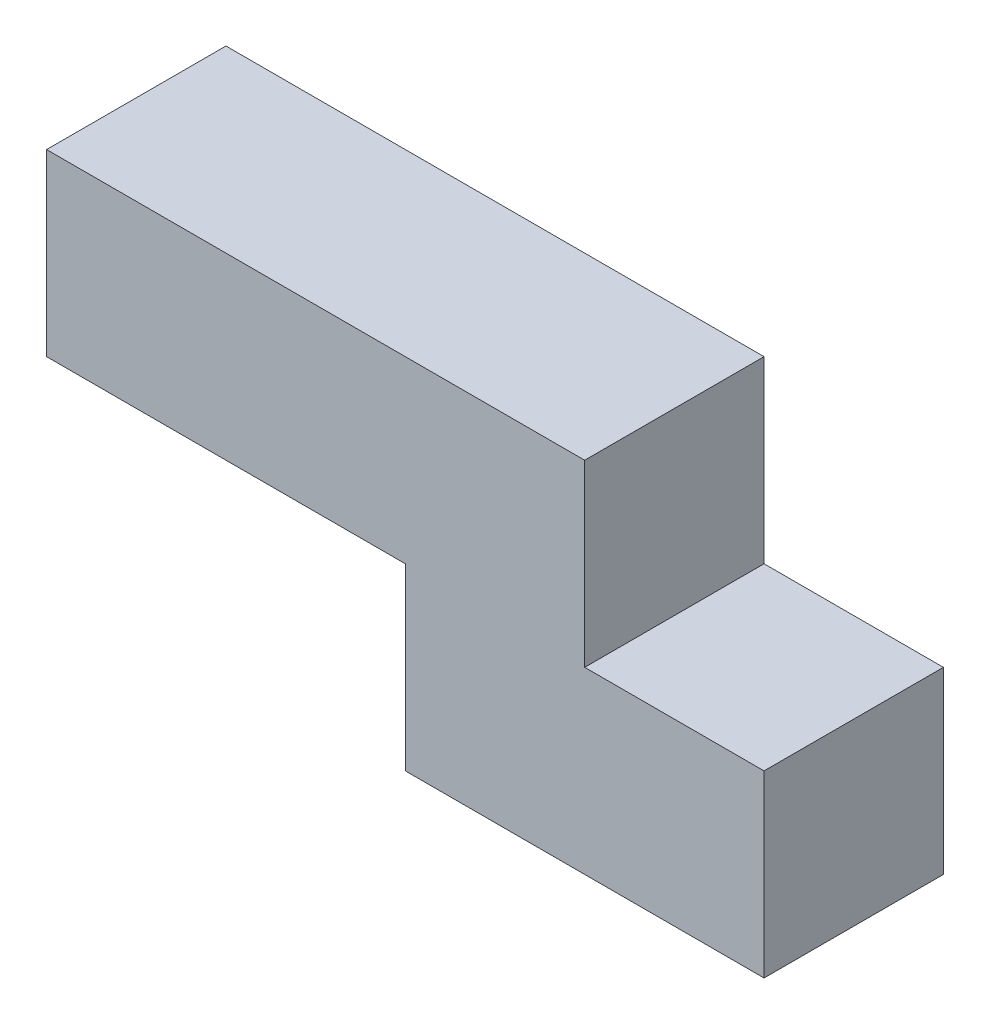
from build123d import *

# Parameters (mm, degrees)
BOSS_EXTRUDE1_DEPTH = 25.4


with BuildPart() as part:
    # Sketch1 → Boss-Extrude1 (new body)
    with BuildSketch(Plane.XY):
        Polygon((101.6, 0), (101.6, 25.4), (76.2, 25.4), (76.2, 50.8), (0, 50.8), (0, 25.4), (50.8, 25.4), (50.8, 0), align=None)
    extrude(amount=BOSS_EXTRUDE1_DEPTH)


solid = part.part
